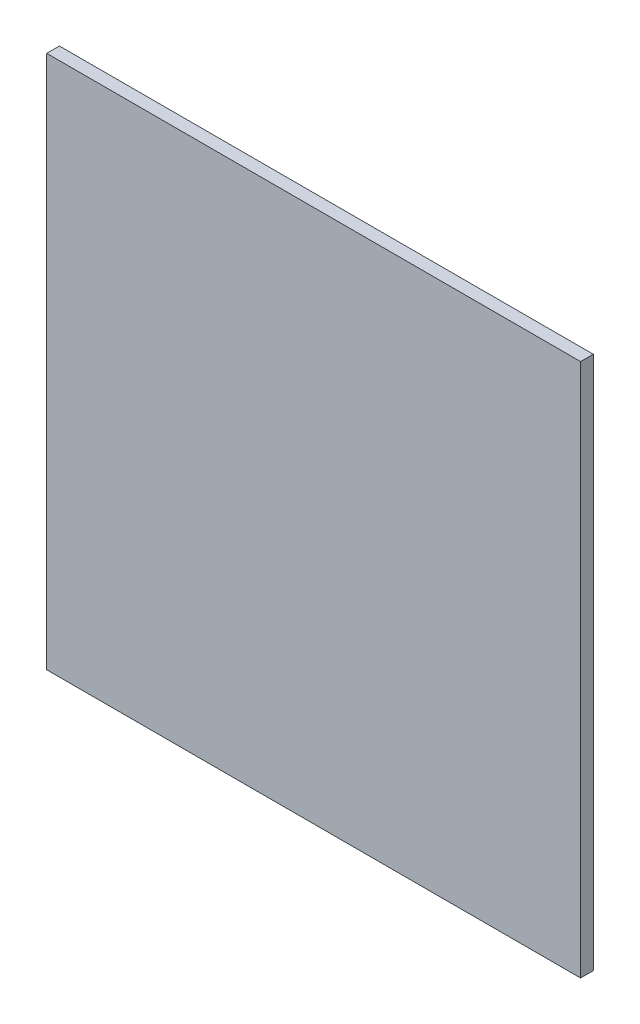
from build123d import *

# Parameters (mm, degrees)
SKETCH1_W           = 106.68
SKETCH1_H           = 106.68
BOSS_EXTRUDE1_DEPTH = 2.54


with BuildPart() as part:
    # Sketch1 → Boss-Extrude1 (new body)
    with BuildSketch(Plane.XY):
        Rectangle(SKETCH1_W, SKETCH1_H)
    extrude(amount=BOSS_EXTRUDE1_DEPTH)


solid = part.part
